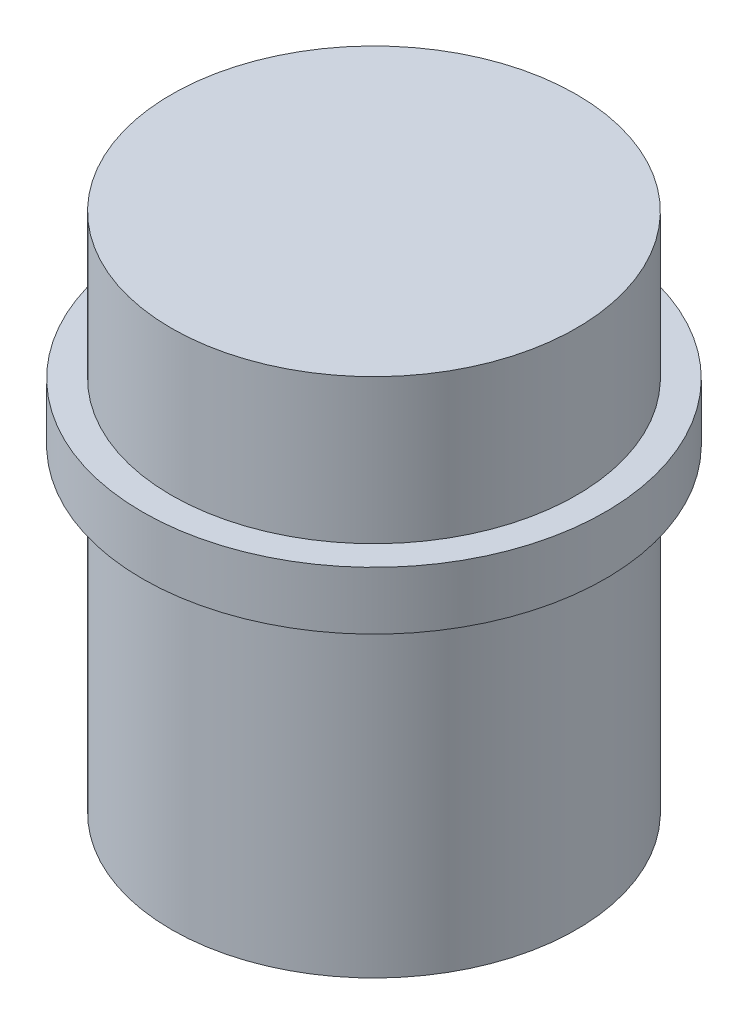
from build123d import *

# Parameters (mm, degrees)
SKETCH1_R                = 8
BOSS_EXTRUDE1_DEPTH      = 2
SKETCH2_R                = 7
BOSS_EXTRUDE2_DEPTH      = 5
BOSS_EXTRUDE2_DEPTH_BACK = 13
SKETCH4_R                = 5
CUT_EXTRUDE2_DEPTH       = 2


with BuildPart() as part:
    # Sketch1 → Boss-Extrude1 (new body)
    with BuildSketch(Plane(origin=(0, 0, 0), x_dir=(1, 0, 0), z_dir=(0, 1, 0))):
        Circle(SKETCH1_R)
    extrude(amount=BOSS_EXTRUDE1_DEPTH)

    # Sketch2 → Boss-Extrude2 (add, two sides)
    with BuildSketch(Plane(origin=(0, 2, 0), x_dir=(1, 0, 0), z_dir=(0, 1, 0))) as boss_extrude2_sk:
        Circle(SKETCH2_R)
    extrude(amount=BOSS_EXTRUDE2_DEPTH)
    extrude(boss_extrude2_sk.sketch, amount=-BOSS_EXTRUDE2_DEPTH_BACK)

    # Sketch4 → Cut-Extrude2 (cut)
    with BuildSketch(Plane.XZ.offset(11)):
        Circle(SKETCH4_R)
    extrude(amount=-CUT_EXTRUDE2_DEPTH, mode=Mode.SUBTRACT)


solid = part.part
